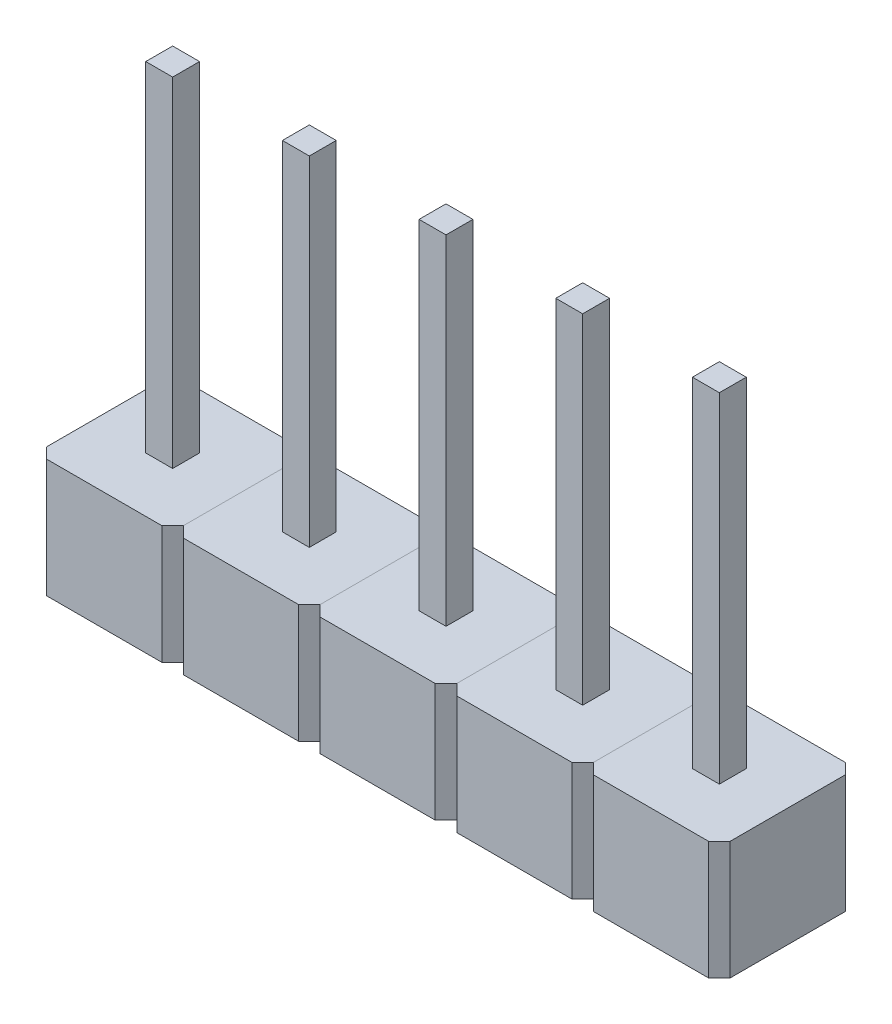
from build123d import *

# Parameters (mm, degrees)
CROQUIS1_W       = 0.5
CROQUIS1_H       = 0.5
EXTRUIR1_DEPTH   = 8.5
EXTRUIR1_2_DEPTH = 8.5
EXTRUIR1_3_DEPTH = 8.5
EXTRUIR1_4_DEPTH = 8.5
EXTRUIR1_5_DEPTH = 8.5
CROQUIS2_W       = 2.54
CROQUIS2_H       = 2.54
CROQUIS2_W_2     = 0.5
CROQUIS2_H_2     = 0.5
EXTRUIR2_DEPTH   = 2.2
CHAFL_N1_SIZE    = 0.2
MATRIZL1_COUNT   = 5
MATRIZL1_PITCH   = 2.54


with BuildPart() as part:
    # Croquis1 → Extruir1 (new body)
    with BuildSketch(Plane(origin=(0, 0, 0), x_dir=(1, 0, 0), z_dir=(0, 1, 0))):
        with Locations((2.79, 0.25)):
            Rectangle(CROQUIS1_W, CROQUIS1_H)
    extrude(amount=EXTRUIR1_DEPTH)


with BuildPart() as body_2:
    # Croquis1 → Extruir1 2 (new body)
    with BuildSketch(Plane(origin=(0, 0, 0), x_dir=(1, 0, 0), z_dir=(0, 1, 0))):
        with Locations((0.25, 0.25)):
            Rectangle(CROQUIS1_W, CROQUIS1_H)
    extrude(amount=EXTRUIR1_2_DEPTH)


with BuildPart() as body_3:
    # Croquis1 → Extruir1 3 (new body)
    with BuildSketch(Plane(origin=(0, 0, 0), x_dir=(1, 0, 0), z_dir=(0, 1, 0))):
        with Locations((5.33, 0.25)):
            Rectangle(CROQUIS1_W, CROQUIS1_H)
    extrude(amount=EXTRUIR1_3_DEPTH)


with BuildPart() as body_4:
    # Croquis1 → Extruir1 4 (new body)
    with BuildSketch(Plane(origin=(0, 0, 0), x_dir=(1, 0, 0), z_dir=(0, 1, 0))):
        with Locations((7.87, 0.25)):
            Rectangle(CROQUIS1_W, CROQUIS1_H)
    extrude(amount=EXTRUIR1_4_DEPTH)


with BuildPart() as body_5:
    # Croquis1 → Extruir1 5 (new body)
    with BuildSketch(Plane(origin=(0, 0, 0), x_dir=(1, 0, 0), z_dir=(0, 1, 0))):
        with Locations((10.41, 0.25)):
            Rectangle(CROQUIS1_W, CROQUIS1_H)
    extrude(amount=EXTRUIR1_5_DEPTH)


with BuildPart() as body_6:
    # Croquis2 → Extruir2 (new body)
    with BuildSketch(Plane.XZ):
        with Locations((0.25, -0.25)):
            Rectangle(CROQUIS2_W, CROQUIS2_H)
        with Locations((0.25, -0.25)):
            Rectangle(CROQUIS2_W_2, CROQUIS2_H_2, mode=Mode.SUBTRACT)
    extrude(amount=-EXTRUIR2_DEPTH)

    # Chaflán1
    chafl_n1_edges = [body_6.edges().sort_by_distance(p)[0] for p in [
        (-1.02, 1.1, 1.02),
        (1.52, 1.1, 1.02),
        (1.52, 1.1, -1.52),
        (-1.02, 1.1, -1.52),
    ]]
    chamfer(chafl_n1_edges, length=CHAFL_N1_SIZE)


with BuildPart() as matrizl1_1:
    # MatrizL1: pattern copy
    add(body_6.part.moved(Location(Vector(1, 0, 0) * (1 * MATRIZL1_PITCH))))


with BuildPart() as matrizl1_2:
    # MatrizL1: pattern copy
    add(body_6.part.moved(Location(Vector(1, 0, 0) * (2 * MATRIZL1_PITCH))))


with BuildPart() as matrizl1_3:
    # MatrizL1: pattern copy
    add(body_6.part.moved(Location(Vector(1, 0, 0) * (3 * MATRIZL1_PITCH))))


with BuildPart() as matrizl1_4:
    # MatrizL1: pattern copy
    add(body_6.part.moved(Location(Vector(1, 0, 0) * (4 * MATRIZL1_PITCH))))


solid = Compound([part.part, body_2.part, body_3.part, body_4.part, body_5.part, body_6.part, matrizl1_1.part, matrizl1_2.part, matrizl1_3.part, matrizl1_4.part])
